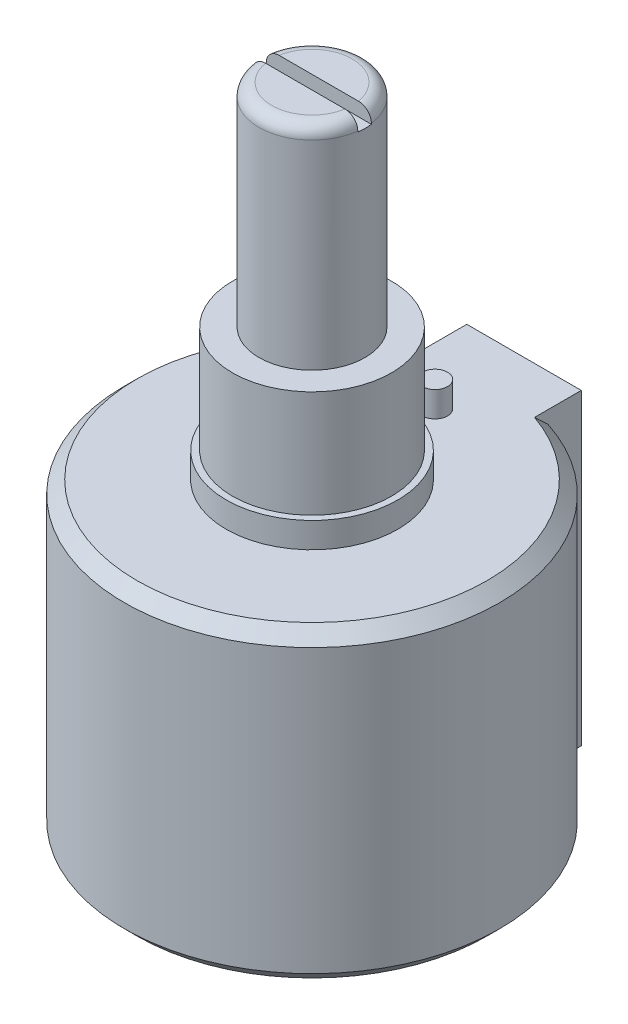
from build123d import *

# Parameters (mm, degrees)
BODY_DEPTH          = 18.4404
SKETCH3_R           = 5.1435
SKETCH3_R_2         = 0.7493
BOSS_EXTRUDE2_DEPTH = 1.524
SKETCH4_R           = 4.7625
MOUNT_LUG_DEPTH     = 6.4008
SKETCH5_R           = 3.175
SHAFT_DEPTH         = 12.7
FILLET1_R           = 0.762
SKETCH6_W           = 0.8128
SKETCH6_H           = 1.6256
ADJ_SLOT_DEPTH      = 12.2395
ADJ_SLOT_DEPTH_BACK = 12.2395
CHAMFER1_SIZE       = 0.762


with BuildPart() as part:
    # Sketch1 → Body (new body)
    with BuildSketch(Plane(origin=(0, 0, 0), x_dir=(1, 0, 0), z_dir=(0, 1, 0))):
        with BuildLine():
            Line((3.429, 12.7), (-3.429, 12.7))
            Line((-3.429, 12.7), (-3.429, 10.703659152))
            ThreePointArc((-3.429, 10.703659152), (0, -11.2395), (3.429, 10.703659152))
            Line((3.429, 10.703659152), (3.429, 12.7))
        make_face()
    extrude(amount=BODY_DEPTH)

    # Sketch3 → Boss-Extrude2 (add)
    with BuildSketch(Plane(origin=(0, 18.4404, 0), x_dir=(1, 0, 0), z_dir=(0, 1, 0))):
        Circle(SKETCH3_R)
        with Locations((0, 7.366)):
            Circle(SKETCH3_R_2)
    extrude(amount=BOSS_EXTRUDE2_DEPTH)

    # Sketch4 → Mount Lug (add)
    with BuildSketch(Plane(origin=(0, 19.9644, 0), x_dir=(1, 0, 0), z_dir=(0, 1, 0))):
        Circle(SKETCH4_R)
    extrude(amount=MOUNT_LUG_DEPTH)

    # Sketch5 → Shaft (add)
    with BuildSketch(Plane(origin=(0, 26.3652, 0), x_dir=(1, 0, 0), z_dir=(0, 1, 0))):
        Circle(SKETCH5_R)
    extrude(amount=SHAFT_DEPTH)

    # Fillet1
    fillet1_edges = [part.edges().sort_by_distance(p)[0] for p in [
        (-3.175, 39.0652, 0),
    ]]
    fillet(fillet1_edges, radius=FILLET1_R)

    # Sketch6 → Adj. slot (cut, two sides)
    with BuildSketch(Plane(origin=(0, 0, 0), x_dir=(0, 0, -1), z_dir=(1, 0, 0))) as adj_slot_sk:
        with Locations((0, 39.0652)):
            Rectangle(SKETCH6_W, SKETCH6_H)
    extrude(amount=ADJ_SLOT_DEPTH, mode=Mode.SUBTRACT)
    extrude(adj_slot_sk.sketch, amount=-ADJ_SLOT_DEPTH_BACK, mode=Mode.SUBTRACT)

    # Chamfer1
    chamfer1_edges = [part.edges().sort_by_distance(p)[0] for p in [
        (0, 18.4404, 11.2395),
        (0, 0, 11.2395),
    ]]
    chamfer(chamfer1_edges, length=CHAMFER1_SIZE)


solid = part.part
